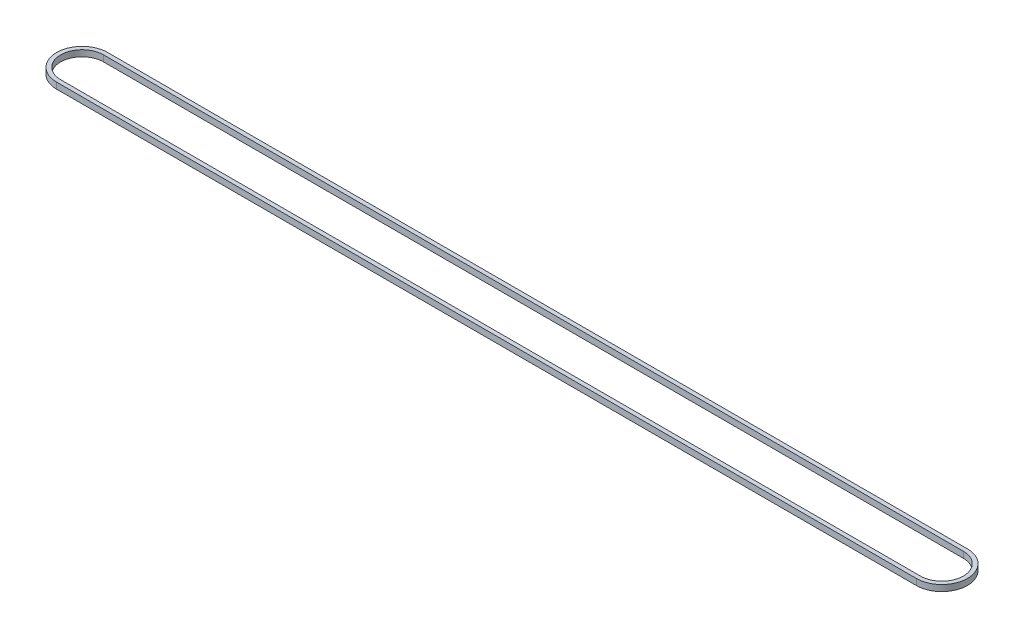
from build123d import *

# Parameters (mm, degrees)
BOSS_EXTRUDE1_DEPTH = 3


with BuildPart() as part:
    # Sketch1 → Boss-Extrude1 (new body)
    with BuildSketch(Plane(origin=(0, 0, 0), x_dir=(1, 0, 0), z_dir=(0, 1, 0))):
        with BuildLine():
            Line((-32.668928407, 12.5), (387.331071593, 12.5))
            ThreePointArc((387.331071593, 12.5), (399.831071593, 0), (387.331071593, -12.5))
            Line((387.331071593, -12.5), (-32.668928407, -12.5))
            ThreePointArc((-32.668928407, -12.5), (-45.168928407, 0), (-32.668928407, 12.5))
        make_face()
        with BuildLine():
            Line((-32.668928407, 10.5), (387.331071593, 10.5))
            ThreePointArc((387.331071593, 10.5), (397.831071593, 0), (387.331071593, -10.5))
            Line((387.331071593, -10.5), (-32.668928407, -10.5))
            ThreePointArc((-32.668928407, -10.5), (-43.168928407, 0), (-32.668928407, 10.5))
        make_face(mode=Mode.SUBTRACT)
    extrude(amount=BOSS_EXTRUDE1_DEPTH)


solid = part.part
